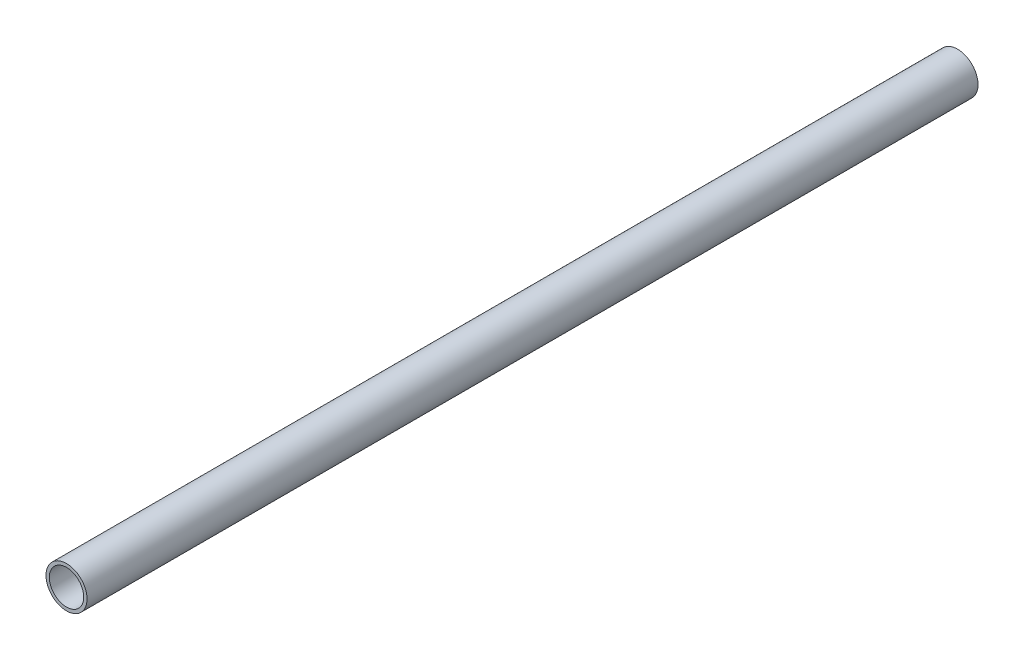
from build123d import *

# Parameters (mm, degrees)
SZKIC1_R                         = 8.35
SZKIC1_R_2                       = 7
DODANIE_WYCI_GNI_CIE1_DEPTH      = 337.570405
DODANIE_WYCI_GNI_CIE1_DEPTH_BACK = 25


with BuildPart() as part:
    # Szkic1 → Dodanie-wyciągnięcie1 (new body, two sides)
    with BuildSketch(Plane.XY) as dodanie_wyci_gni_cie1_sk:
        Circle(SZKIC1_R)
        Circle(SZKIC1_R_2, mode=Mode.SUBTRACT)
    extrude(amount=DODANIE_WYCI_GNI_CIE1_DEPTH)
    extrude(dodanie_wyci_gni_cie1_sk.sketch, amount=-DODANIE_WYCI_GNI_CIE1_DEPTH_BACK)


solid = part.part
